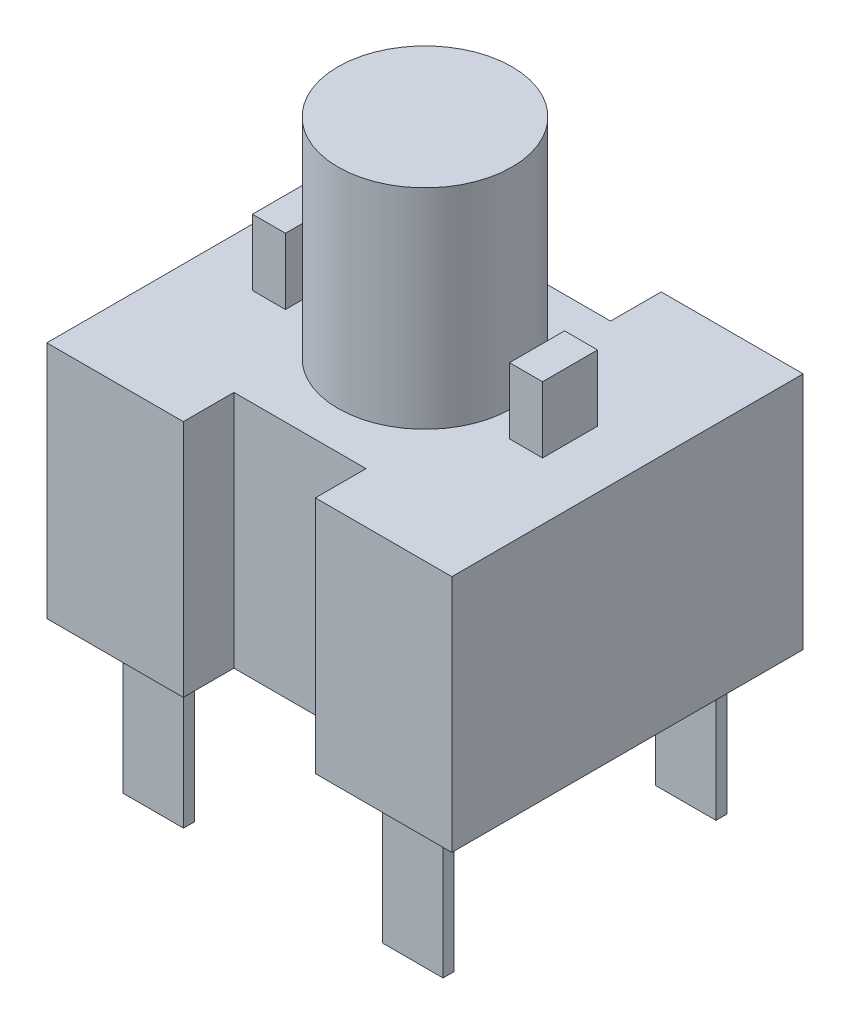
from build123d import *

# Parameters (mm, degrees)
SKETCH1_W           = 18.4
SKETCH1_H           = 15.96
BOSS_EXTRUDE1_DEPTH = 10.85
SKETCH2_W           = 2.75
SKETCH2_H           = 0.5
BOSS_EXTRUDE2_DEPTH = 6.67
SKETCH3_W           = 5.5
SKETCH3_H           = 2.3
SKETCH3_W_2         = 6
CUT_EXTRUDE1_DEPTH  = 18.52
SKETCH4_R           = 3.95
BOSS_EXTRUDE3_DEPTH = 9.5
SKETCH5_W           = 1.5
SKETCH5_H           = 2.5
BOSS_EXTRUDE4_DEPTH = 3


with BuildPart() as part:
    # Sketch1 → Boss-Extrude1 (new body)
    with BuildSketch(Plane(origin=(0, 0, 0), x_dir=(1, 0, 0), z_dir=(0, 1, 0))):
        Rectangle(SKETCH1_W, SKETCH1_H)
    extrude(amount=BOSS_EXTRUDE1_DEPTH)

    # Sketch2 → Boss-Extrude2 (add)
    with BuildSketch(Plane.XZ):
        with Locations((-5.895, -6.2)):
            Rectangle(SKETCH2_W, SKETCH2_H)
        with Locations((-5.895, 6.2)):
            Rectangle(SKETCH2_W, SKETCH2_H)
        with Locations((5.895, -6.2)):
            Rectangle(SKETCH2_W, SKETCH2_H)
        with Locations((5.895, 6.2)):
            Rectangle(SKETCH2_W, SKETCH2_H)
    extrude(amount=BOSS_EXTRUDE2_DEPTH)

    # Sketch3 → Cut-Extrude1 (cut, through all)
    with BuildSketch(Plane(origin=(0, 10.85, 0), x_dir=(1, 0, 0), z_dir=(0, 1, 0))):
        with Locations((0, 6.83)):
            Rectangle(SKETCH3_W, SKETCH3_H)
        with Locations((0, -6.83)):
            Rectangle(SKETCH3_W_2, SKETCH3_H)
    extrude(amount=-CUT_EXTRUDE1_DEPTH, mode=Mode.SUBTRACT)

    # Sketch4 → Boss-Extrude3 (add)
    with BuildSketch(Plane(origin=(0, 10.85, 0), x_dir=(1, 0, 0), z_dir=(0, 1, 0))):
        Circle(SKETCH4_R)
    extrude(amount=BOSS_EXTRUDE3_DEPTH)

    # Sketch5 → Boss-Extrude4 (add)
    with BuildSketch(Plane(origin=(0, 10.85, 0), x_dir=(1, 0, 0), z_dir=(0, 1, 0))):
        with Locations((-5.84, 0)):
            Rectangle(SKETCH5_W, SKETCH5_H)
        with Locations((5.84, 0)):
            Rectangle(SKETCH5_W, SKETCH5_H)
    extrude(amount=BOSS_EXTRUDE4_DEPTH)


solid = part.part
